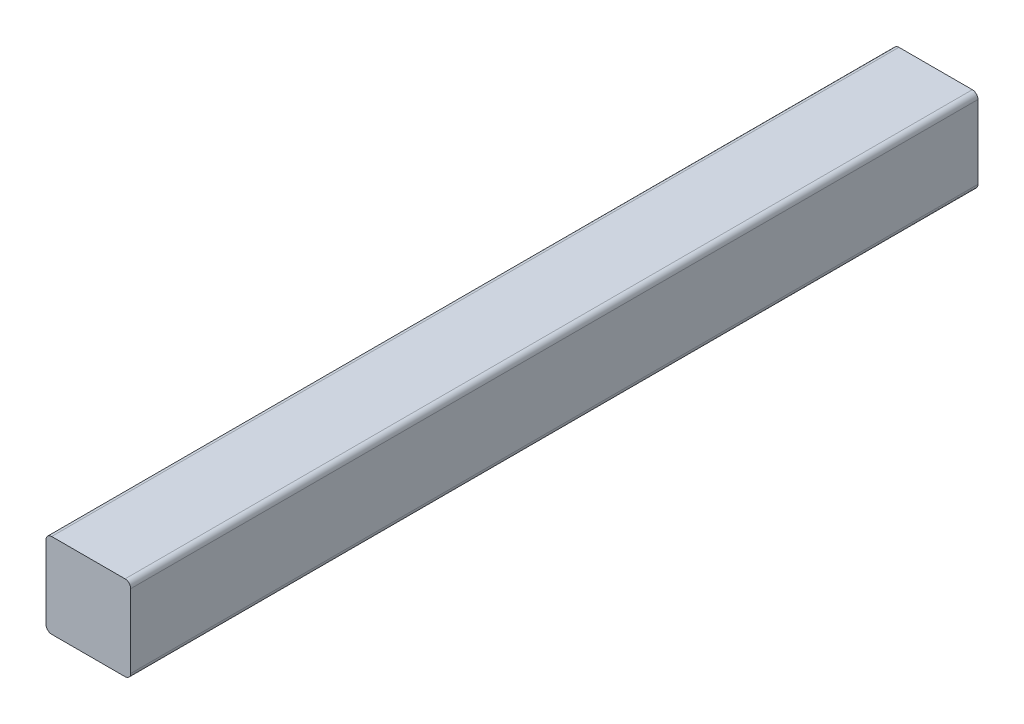
from build123d import *

# Parameters (mm, degrees)
BOSS_EXTRUDE1_DEPTH = 300


with BuildPart() as part:
    # Sketch3 → Boss-Extrude1 (new body)
    with BuildSketch(Plane.XY):
        with BuildLine():
            Line((2, 0), (28, 0))
            ThreePointArc((28, 0), (29.414213562, 0.585786438), (30, 2))
            Line((30, 2), (30, 28))
            ThreePointArc((30, 28), (29.414213562, 29.414213562), (28, 30))
            Line((28, 30), (2, 30))
            ThreePointArc((2, 30), (0.585786438, 29.414213562), (0, 28))
            Line((0, 28), (0, 2))
            ThreePointArc((0, 2), (0.585786438, 0.585786438), (2, 0))
        make_face()
    extrude(amount=BOSS_EXTRUDE1_DEPTH)


solid = part.part
